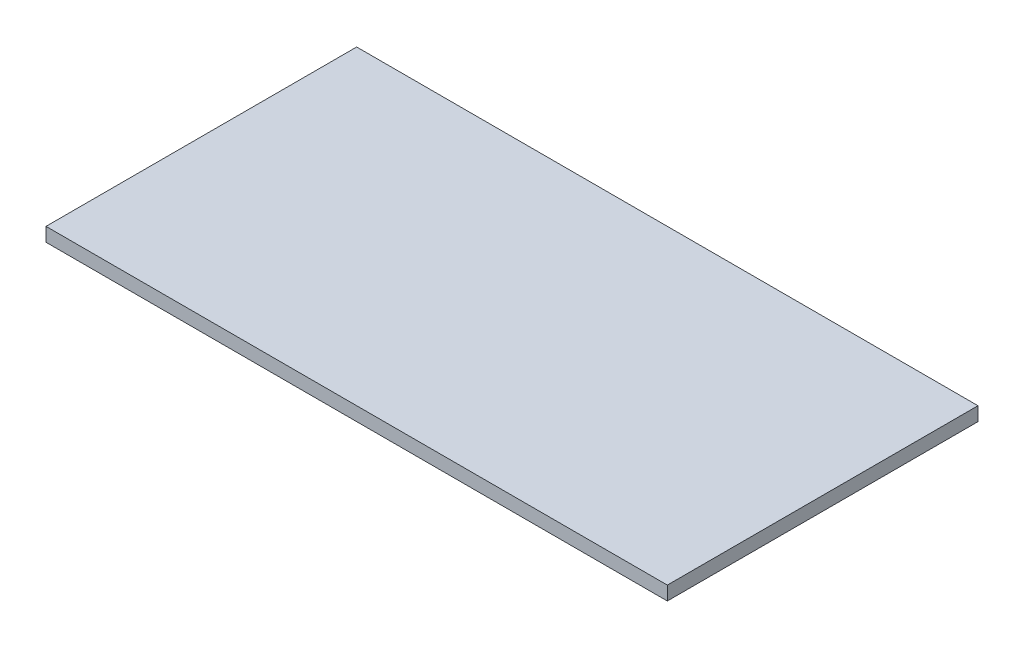
from build123d import *

# Parameters (mm, degrees)
SKETCH1_W           = 180
SKETCH1_H           = 90
BOSS_EXTRUDE1_DEPTH = 4


with BuildPart() as part:
    # Sketch1 → Boss-Extrude1 (new body)
    with BuildSketch(Plane(origin=(0, 0, 0), x_dir=(1, 0, 0), z_dir=(0, 1, 0))):
        Rectangle(SKETCH1_W, SKETCH1_H)
    extrude(amount=BOSS_EXTRUDE1_DEPTH)


solid = part.part
